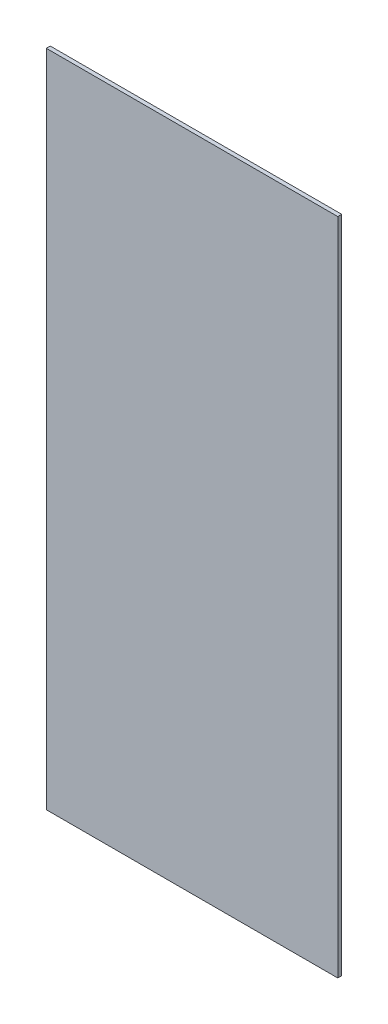
from build123d import *

# Parameters (mm, degrees)
SKETCH1_W                 = 112.268
SKETCH1_H                 = 254
BOTTOM_OUTER_CASING_DEPTH = 1.51892


with BuildPart() as part:
    # Sketch1 → Bottom Outer Casing (new body)
    with BuildSketch(Plane.XY):
        with Locations((56.134, 127)):
            Rectangle(SKETCH1_W, SKETCH1_H)
    extrude(amount=BOTTOM_OUTER_CASING_DEPTH)


solid = part.part
